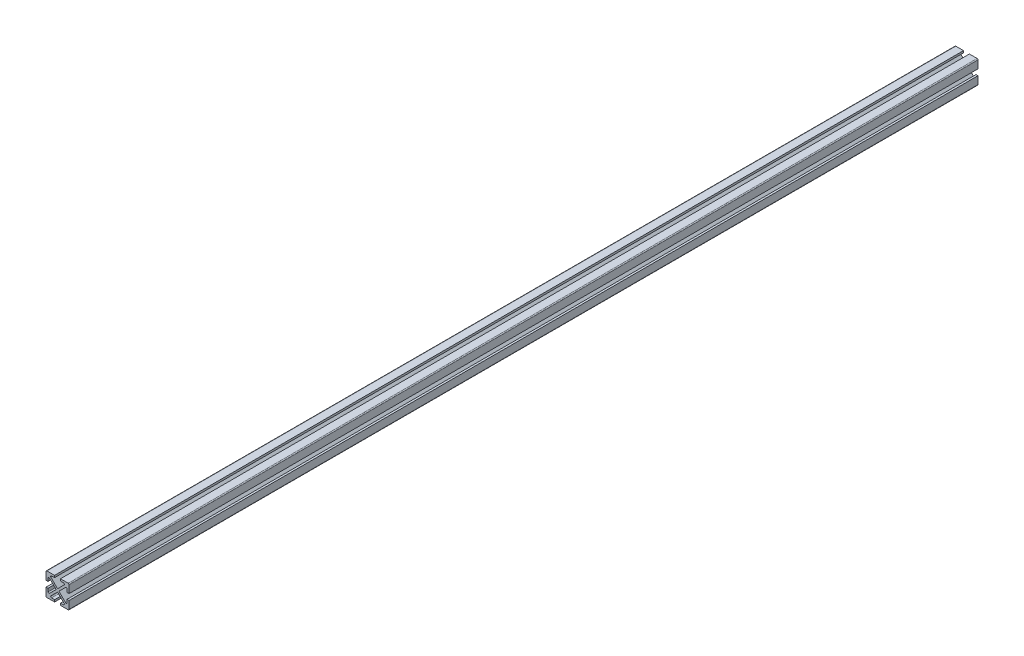
from build123d import *

# Parameters (mm, degrees)
BOSS_EXTRUDE1_DEPTH = 500
FILLET1_R           = 1


with BuildPart() as part:
    # Sketch1 → Boss-Extrude1 (new body, symmetric)
    with BuildSketch(Plane.XY):
        Polygon((-3.2512, 10.4902), (-3.2512, 12.7), (-12.7, 12.7), (-12.7, 3.2512), (-10.4902, 3.2512), (-10.4902, 8.927635435), (-1.562564565, 0), (-10.4902, -8.927635435), (-10.4902, -3.2512), (-12.7, -3.2512), (-12.7, -12.7), (-3.2512, -12.7), (-3.2512, -10.4902), (-8.927635435, -10.4902), (0, -1.562564565), (8.927635435, -10.4902), (3.2512, -10.4902), (3.2512, -12.7), (12.7, -12.7), (12.7, -3.2512), (10.4902, -3.2512), (10.4902, -8.927635435), (1.562564565, 0), (10.4902, 8.927635435), (10.4902, 3.2512), (12.7, 3.2512), (12.7, 12.7), (3.2512, 12.7), (3.2512, 10.4902), (8.927635435, 10.4902), (0, 1.562564565), (-8.927635435, 10.4902), align=None)
    extrude(amount=BOSS_EXTRUDE1_DEPTH, both=True)

    # Fillet1
    fillet1_edges = [part.edges().sort_by_distance(p)[0] for p in [
        (-10.4902, 8.927635435, 0),
        (-12.7, 12.7, 0),
        (-8.927635435, 10.4902, 0),
        (8.927635435, 10.4902, 0),
        (12.7, 12.7, 0),
        (10.4902, 8.927635435, 0),
        (10.4902, -8.927635435, 0),
        (12.7, -12.7, 0),
        (8.927635435, -10.4902, 0),
        (-8.927635435, -10.4902, 0),
        (-12.7, -12.7, 0),
        (-10.4902, -8.927635435, 0),
    ]]
    fillet(fillet1_edges, radius=FILLET1_R)


solid = part.part
